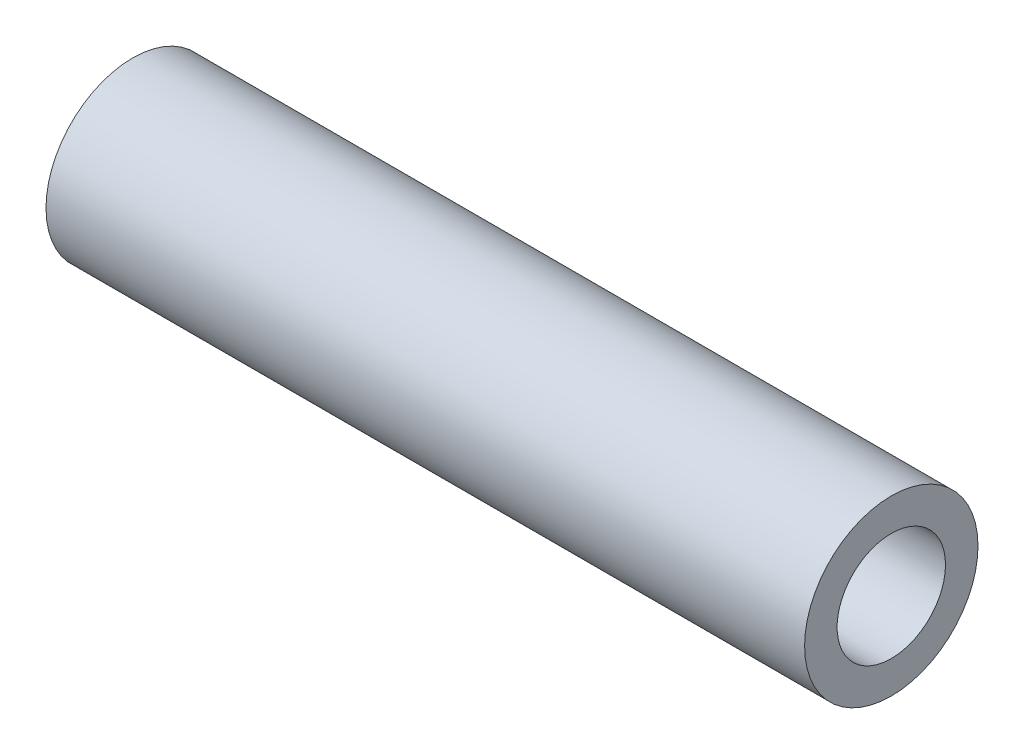
from build123d import *

# Parameters (mm, degrees)
SKETCH1_R           = 8
SKETCH1_R_2         = 5
BOSS_EXTRUDE1_DEPTH = 70


with BuildPart() as part:
    # Sketch1 → Boss-Extrude1 (new body)
    with BuildSketch(Plane(origin=(0, 0, 0), x_dir=(0, 0, -1), z_dir=(1, 0, 0))):
        Circle(SKETCH1_R)
        Circle(SKETCH1_R_2, mode=Mode.SUBTRACT)
    extrude(amount=BOSS_EXTRUDE1_DEPTH)


solid = part.part
